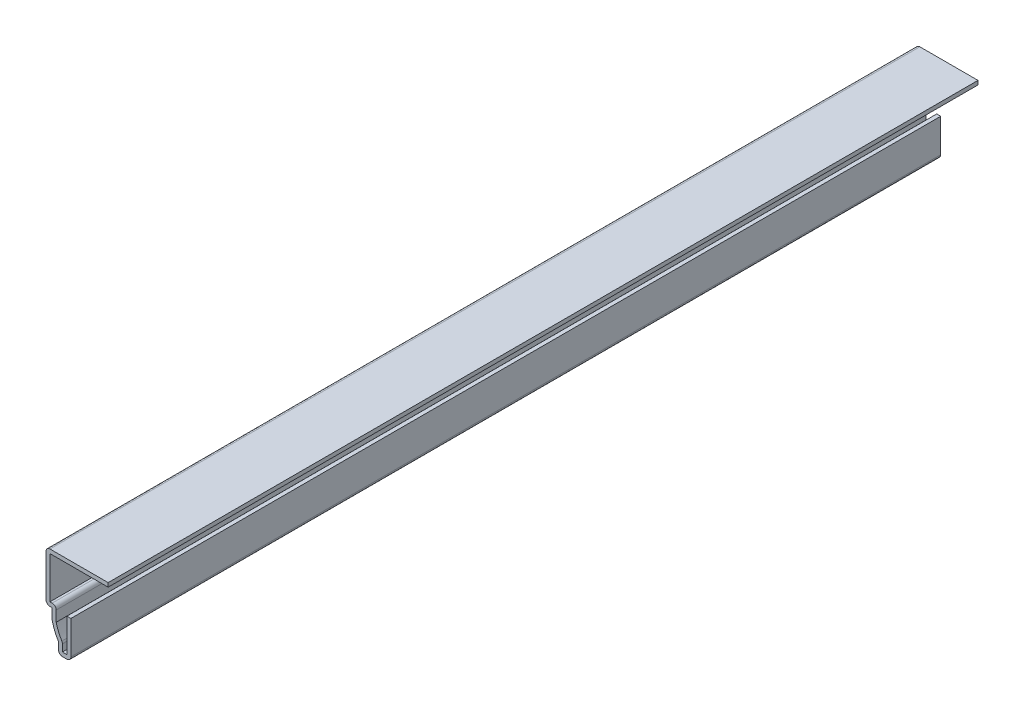
from build123d import *

# Parameters (mm, degrees)
EXTRUDE_THIN1_DEPTH = 222.25
FILLET1_R           = 1.016


with BuildPart() as part:
    # Sketch1 → Extrude-Thin1 (new body)
    with BuildSketch(Plane.XY):
        with BuildLine():
            Line((0, 0), (0, -9.525))
            Line((0, -9.525), (-3.175, -9.525))
            Line((-3.175, -9.525), (-3.175, -6.693600755))
            ThreePointArc((-3.175, -6.693600755), (-4.128572785, -4.828192758), (-4.7625, -2.831399245))
            Line((-4.7625, -2.831399245), (-4.7625, 0))
            Line((-4.7625, 0), (-6.35, 0))
            Line((-6.35, 0), (-6.35, 12.7))
            Line((-6.35, 12.7), (9.525, 12.7))
            Line((9.525, 12.7), (9.525, 11.684))
            Line((9.525, 11.684), (-5.334, 11.684))
            Line((-5.334, 11.684), (-5.334, 1.016))
            Line((-5.334, 1.016), (-3.7465, 1.016))
            Line((-3.7465, 1.016), (-3.7465, -2.714277453))
            ThreePointArc((-3.7465, -2.714277453), (-3.111980098, -4.624554555), (-2.159, -6.397575437))
            Line((-2.159, -6.397575437), (-2.159, -8.509))
            Line((-2.159, -8.509), (-1.016, -8.509))
            Line((-1.016, -8.509), (-1.016, 0))
            Line((-1.016, 0), (0, 0))
        make_face()
    extrude(amount=-EXTRUDE_THIN1_DEPTH)

    # Fillet1
    fillet1_edges = [part.edges().sort_by_distance(p)[0] for p in [
        (-3.7465, 1.016, -111.125),
        (-2.159, -6.397575437, -111.125),
        (0, -9.525, -111.125),
        (-3.175, -9.525, -111.125),
        (-4.7625, -2.831399245, -111.125),
        (-6.35, 0, -111.125),
        (-6.35, 12.7, -111.125),
    ]]
    fillet(fillet1_edges, radius=FILLET1_R)


solid = part.part
